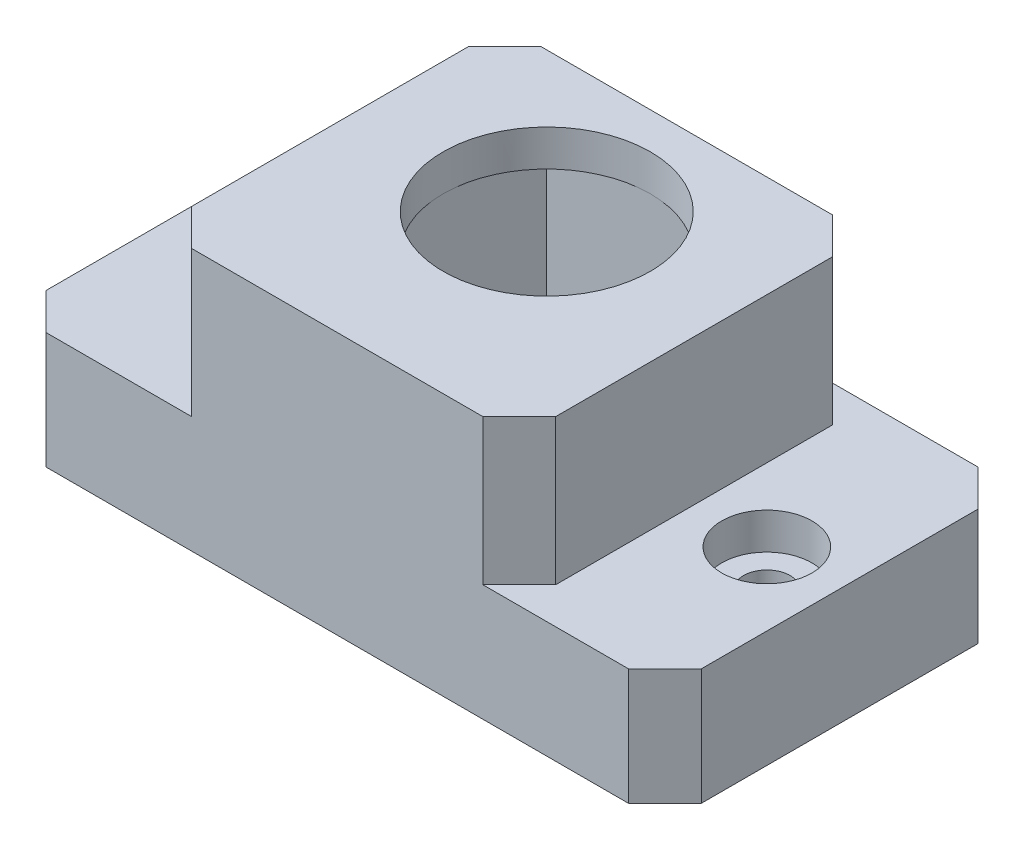
from build123d import *

# Parameters (mm, degrees)
SKETCH1_W           = 45
SKETCH1_H           = 24
BOSS_EXTRUDE1_DEPTH = 18
SKETCH2_W           = 10
SKETCH2_H           = 24
CUT_EXTRUDE1_DEPTH  = 10
SKETCH3_R           = 1.6
CUT_EXTRUDE2_DEPTH  = 9
SKETCH4_R           = 3.1
CUT_EXTRUDE3_DEPTH  = 2.5
SKETCH5_W           = 14.23
SKETCH5_H           = 19
CUT_EXTRUDE4_DEPTH  = 15.5
SKETCH6_R           = 7.115
CUT_EXTRUDE5_DEPTH  = 3.5
CHAMFER1_SIZE       = 2.5


with BuildPart() as part:
    # Sketch1 → Boss-Extrude1 (new body)
    with BuildSketch(Plane(origin=(0, 0, 0), x_dir=(1, 0, 0), z_dir=(0, 1, 0))):
        Rectangle(SKETCH1_W, SKETCH1_H)
    extrude(amount=BOSS_EXTRUDE1_DEPTH)

    # Sketch2 → Cut-Extrude1 (cut)
    with BuildSketch(Plane(origin=(0, 18, 0), x_dir=(1, 0, 0), z_dir=(0, 1, 0))):
        with Locations((-17.5, 0)):
            Rectangle(SKETCH2_W, SKETCH2_H)
        with Locations((17.5, 0)):
            Rectangle(SKETCH2_W, SKETCH2_H)
    extrude(amount=-CUT_EXTRUDE1_DEPTH, mode=Mode.SUBTRACT)

    # Sketch3 → Cut-Extrude2 (cut, through all)
    with BuildSketch(Plane(origin=(0, 8, 0), x_dir=(1, 0, 0), z_dir=(0, 1, 0))):
        with Locations((-17.5, 0)):
            Circle(SKETCH3_R)
        with Locations((17.5, 0)):
            Circle(SKETCH3_R)
    extrude(amount=-CUT_EXTRUDE2_DEPTH, mode=Mode.SUBTRACT)

    # Sketch4 → Cut-Extrude3 (cut)
    with BuildSketch(Plane(origin=(0, 8, 0), x_dir=(1, 0, 0), z_dir=(0, 1, 0))):
        with Locations((-17.5, 0)):
            Circle(SKETCH4_R)
        with Locations((17.5, 0)):
            Circle(SKETCH4_R)
    extrude(amount=-CUT_EXTRUDE3_DEPTH, mode=Mode.SUBTRACT)

    # Sketch5 → Cut-Extrude4 (cut)
    with BuildSketch(Plane.XZ):
        Rectangle(SKETCH5_W, SKETCH5_H)
    extrude(amount=-CUT_EXTRUDE4_DEPTH, mode=Mode.SUBTRACT)

    # Sketch6 → Cut-Extrude5 (cut, through all)
    with BuildSketch(Plane.XZ.offset(-15.5)):
        with Locations((0, -2.385)):
            Circle(SKETCH6_R)
    extrude(amount=-CUT_EXTRUDE5_DEPTH, mode=Mode.SUBTRACT)

    # Chamfer1
    chamfer1_edges = [part.edges().sort_by_distance(p)[0] for p in [
        (-22.5, 4, -12),
        (22.5, 4, -12),
        (22.5, 4, 12),
        (-22.5, 4, 12),
        (-12.5, 13, 12),
        (-12.5, 13, -12),
        (12.5, 13, -12),
        (12.5, 13, 12),
    ]]
    chamfer(chamfer1_edges, length=CHAMFER1_SIZE)


solid = part.part
